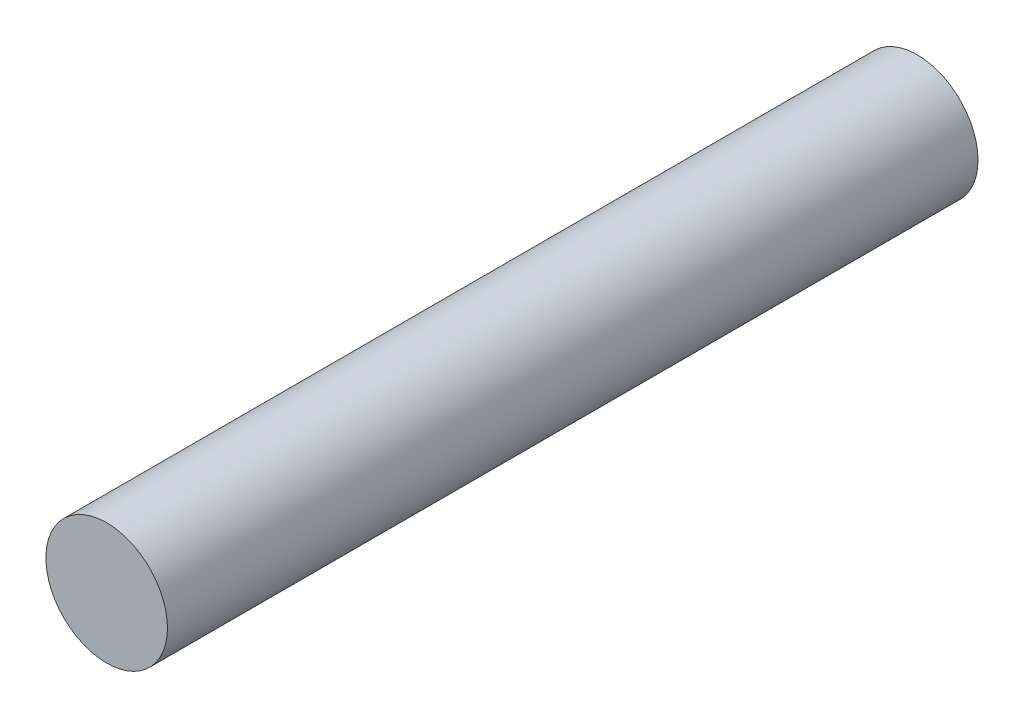
from build123d import *

# Parameters (mm, degrees)
SKETCH1_R           = 19.05
BOSS_EXTRUDE1_DEPTH = 254


with BuildPart() as part:
    # Sketch1 → Boss-Extrude1 (new body)
    with BuildSketch(Plane.XY):
        Circle(SKETCH1_R)
    extrude(amount=BOSS_EXTRUDE1_DEPTH)


solid = part.part
